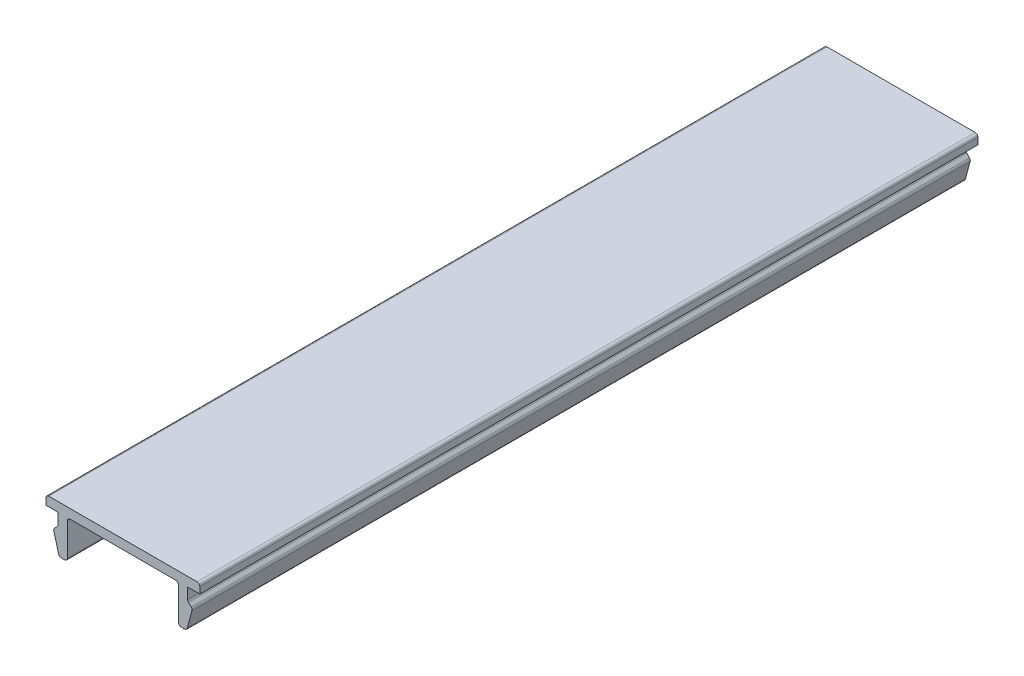
from build123d import *

# Parameters (mm, degrees)
BOSS_EXTRUDE1_DEPTH = 84
FILLET1_R           = 0.3


with BuildPart() as part:
    # Sketch1 → Boss-Extrude1 (new body)
    with BuildSketch(Plane.XY):
        Polygon((-8.3, 1), (8.3, 1), (8.3, 0), (7, 0), (7, -1.3), (7.5, -1.8), (6.883716857, -4.1), (6, -4.1), (6, 0), (-6, 0), (-6, -4.1), (-6.883716857, -4.1), (-7.5, -1.8), (-7, -1.3), (-7, 0), (-8.3, 0), align=None)
    extrude(amount=BOSS_EXTRUDE1_DEPTH)

    # Fillet1
    fillet1_edges = [part.edges().sort_by_distance(p)[0] for p in [
        (-8.3, 1, 42),
        (8.3, 1, 42),
        (7, -1.3, 42),
        (7.5, -1.8, 42),
        (6.883716857, -4.1, 42),
        (6, -4.1, 42),
        (6, 0, 42),
        (-6, 0, 42),
        (-6, -4.1, 42),
        (-6.883716857, -4.1, 42),
        (-7.5, -1.8, 42),
        (-7, -1.3, 42),
    ]]
    fillet(fillet1_edges, radius=FILLET1_R)


solid = part.part
